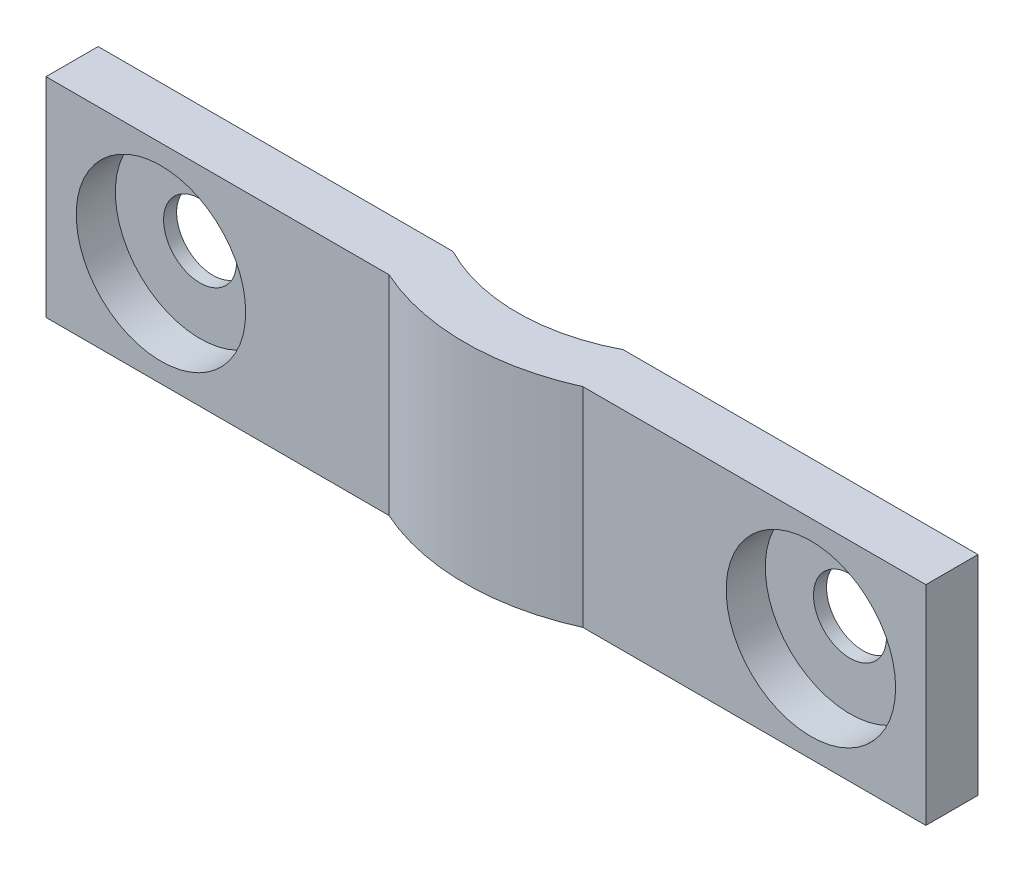
from build123d import *

# Parameters (mm, degrees)
SALIENTE_EXTRUIR3_DEPTH = 4
CROQUIS4_W              = 2
CROQUIS4_H              = 8
SALIENTE_EXTRUIR5_DEPTH = 13.154785
CROQUIS5_R              = 3.25
CORTAR_EXTRUIR1_DEPTH   = 1.5
CORTAR_EXTRUIR2_REACH   = 2.5
CROQUIS6_R              = 1.4


with BuildPart() as part:
    # Croquis3 → Saliente-Extruir3 (new body, symmetric)
    with BuildSketch(Plane(origin=(0, 45.994416346, 0), x_dir=(1, 0, 0), z_dir=(0, 1, 0))):
        with BuildLine():
            ThreePointArc((-58.564503824, 0), (-52.019276555, -2.8), (-45.474049286, 0))
            Line((-45.474049286, 0), (-48.757375269, 0))
            ThreePointArc((-48.757375269, 0), (-52.019276555, -0.8), (-55.281177841, 0))
            Line((-55.281177841, 0), (-58.564503824, 0))
        make_face()
    extrude(amount=SALIENTE_EXTRUIR3_DEPTH, both=True)

    # Croquis4 → Saliente-Extruir5 (add)
    with BuildSketch(Plane(origin=(-68.894276555, 0, 0), x_dir=(0, 0, -1), z_dir=(1, 0, 0))):
        with Locations((-1, 45.994416346)):
            Rectangle(CROQUIS4_W, CROQUIS4_H)
    saliente_extruir5 = extrude(amount=SALIENTE_EXTRUIR5_DEPTH)

    # Simetría1: Saliente-Extruir5 across plane
    add(saliente_extruir5.mirror(Plane(origin=(-52.019276555, 0, 0), x_dir=(0, 0, 1), z_dir=(1, 0, 0))))

    # Croquis5 → Cortar-Extruir1 (cut)
    with BuildSketch(Plane.XY.offset(2)):
        with Locations((-39.554276555, 45.994416346)):
            Circle(CROQUIS5_R)
        with Locations((-64.484276555, 45.994416346)):
            Circle(CROQUIS5_R)
    extrude(amount=-CORTAR_EXTRUIR1_DEPTH, mode=Mode.SUBTRACT)

    # Croquis6 → Cortar-Extruir2 (cut, up to next)
    with BuildSketch(Plane.XY.offset(0.5), mode=Mode.PRIVATE) as cortar_extruir2_sk1:
        with Locations((-39.554276555, 45.994416346)):
            Circle(CROQUIS6_R)
    cortar_extruir2_tool1 = extrude(cortar_extruir2_sk1.sketch, amount=-CORTAR_EXTRUIR2_REACH, mode=Mode.PRIVATE) & part.part
    add(cortar_extruir2_tool1.solids().sort_by_distance((-39.554277, 45.994416, 0.5))[0], mode=Mode.SUBTRACT)
    # Croquis6 → Cortar-Extruir2 (cut, up to next)
    with BuildSketch(Plane.XY.offset(0.5), mode=Mode.PRIVATE) as cortar_extruir2_sk2:
        with Locations((-64.484276555, 45.994416346)):
            Circle(CROQUIS6_R)
    cortar_extruir2_tool2 = extrude(cortar_extruir2_sk2.sketch, amount=-CORTAR_EXTRUIR2_REACH, mode=Mode.PRIVATE) & part.part
    add(cortar_extruir2_tool2.solids().sort_by_distance((-64.484277, 45.994416, 0.5))[0], mode=Mode.SUBTRACT)


solid = part.part
